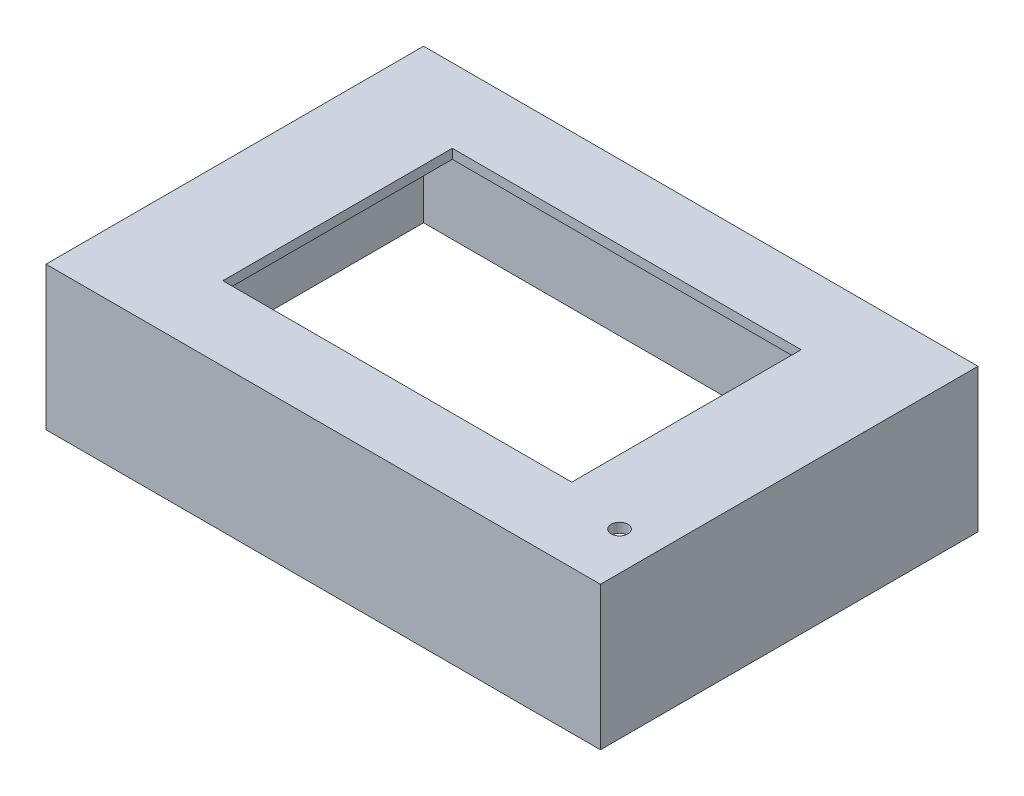
from build123d import *

# Parameters (mm, degrees)
SKETCH1_W           = 116
SKETCH1_H           = 79
SKETCH1_W_2         = 112
SKETCH1_H_2         = 75
BOSS_EXTRUDE1_DEPTH = 28
SKETCH2_W           = 116
SKETCH2_H           = 79
BOSS_EXTRUDE2_DEPTH = 2
SKETCH3_W           = 73
SKETCH3_H           = 48
CUT_EXTRUDE1_DEPTH  = 2
SKETCH4_R           = 1.75
CUT_EXTRUDE2_DEPTH  = 2


with BuildPart() as part:
    # Sketch1 → Boss-Extrude1 (new body)
    with BuildSketch(Plane(origin=(0, 0, 0), x_dir=(1, 0, 0), z_dir=(0, 1, 0))):
        Rectangle(SKETCH1_W, SKETCH1_H)
        Rectangle(SKETCH1_W_2, SKETCH1_H_2, mode=Mode.SUBTRACT)
    extrude(amount=BOSS_EXTRUDE1_DEPTH)

    # Sketch2 → Boss-Extrude2 (add)
    with BuildSketch(Plane(origin=(0, 28, 0), x_dir=(1, 0, 0), z_dir=(0, 1, 0))):
        Rectangle(SKETCH2_W, SKETCH2_H)
    extrude(amount=BOSS_EXTRUDE2_DEPTH)

    # Sketch3 → Cut-Extrude1 (cut)
    with BuildSketch(Plane(origin=(0, 30, 0), x_dir=(1, 0, 0), z_dir=(0, 1, 0))):
        Rectangle(SKETCH3_W, SKETCH3_H)
    extrude(amount=-CUT_EXTRUDE1_DEPTH, mode=Mode.SUBTRACT)

    # Sketch4 → Cut-Extrude2 (cut)
    with BuildSketch(Plane(origin=(0, 30, 0), x_dir=(1, 0, 0), z_dir=(0, 1, 0))):
        with Locations((50, -27.5)):
            Circle(SKETCH4_R)
    extrude(amount=-CUT_EXTRUDE2_DEPTH, mode=Mode.SUBTRACT)


solid = part.part
